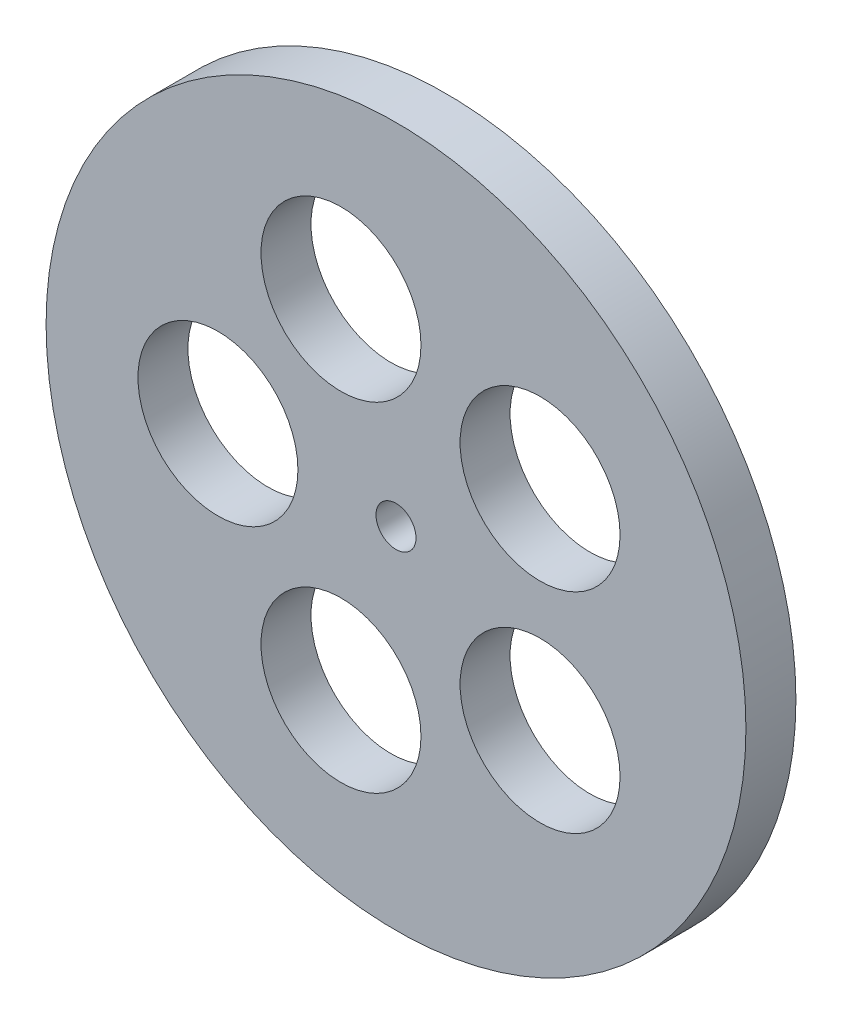
from build123d import *

# Parameters (mm, degrees)
ESQUISSE1_R             = 35
ESQUISSE1_R_2           = 2
CIRCONFERENCE_DEPTH     = 5
ESQUISSE2_R             = 8
ENL_V_MAT_EXTRU_1_DEPTH = 6


with BuildPart() as part:
    # Esquisse1 → circonference (new body)
    with BuildSketch(Plane.XY):
        Circle(ESQUISSE1_R)
        Circle(ESQUISSE1_R_2, mode=Mode.SUBTRACT)
    extrude(amount=CIRCONFERENCE_DEPTH)

    # Esquisse2 → Enlèv. mat.-Extru.1 (cut, through all)
    with BuildSketch(Plane.XY.offset(5)):
        with Locations((-17.810269486, 0)):
            Circle(ESQUISSE2_R)
        with Locations((-5.503675945, 16.938572851)):
            Circle(ESQUISSE2_R)
        with Locations((14.408810688, 10.468613743)):
            Circle(ESQUISSE2_R)
        with Locations((14.408810688, -10.468613743)):
            Circle(ESQUISSE2_R)
        with Locations((-5.503675945, -16.938572851)):
            Circle(ESQUISSE2_R)
    extrude(amount=-ENL_V_MAT_EXTRU_1_DEPTH, mode=Mode.SUBTRACT)


solid = part.part
